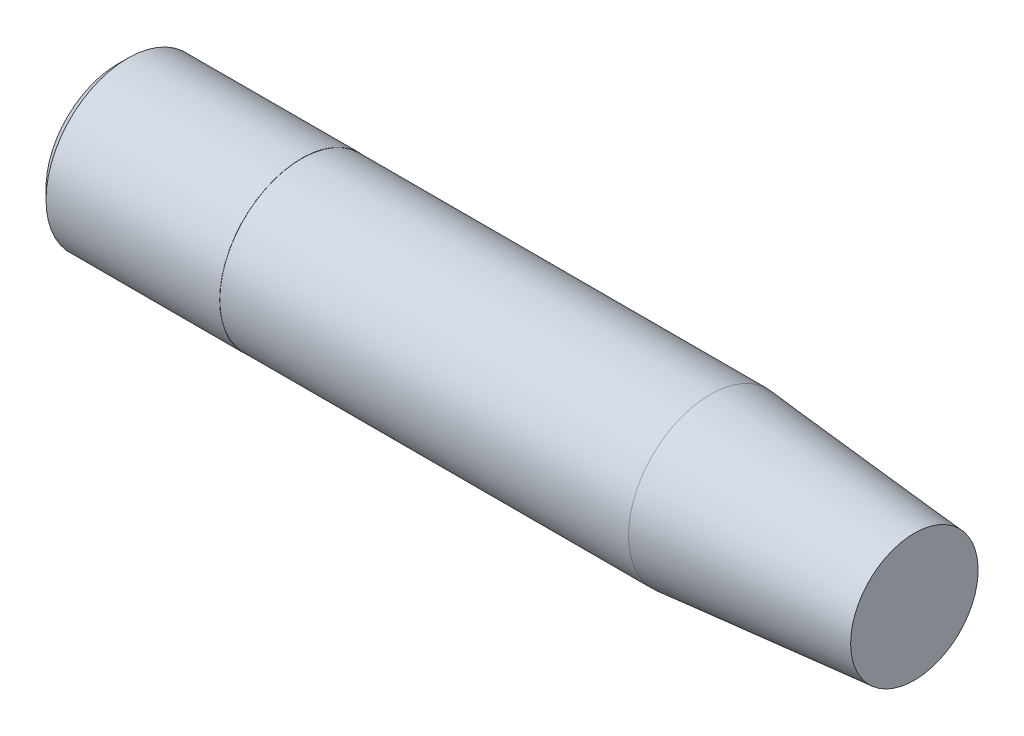
from build123d import *

# Parameters (mm, degrees)
FILLET1_R = 0.25


with BuildPart() as part:
    # Sketch1 → Revolve1 (revolve)
    with BuildSketch(Plane.XY, mode=Mode.PRIVATE) as revolve1_sk:
        Polygon((0, 2.0025), (0, 3.5), (-1, 3.5), (-1, 0), (19.5, 0), (19.5, 1.560056682), (14.5, 1.9975), (4.5, 1.9975), (4.5, 2.0025), align=None)
    revolve(revolve1_sk.sketch.rotate(Axis((-30.167084044, 0, 0), (1, 0, 0)), 90), axis=Axis((-30.167084044, 0, 0), (1, 0, 0)))  # turned: the seam where the file's is

    # Fillet1
    fillet1_edges = [part.edges().sort_by_distance(p)[0] for p in [
        (0, 0, -2.0025),
    ]]
    fillet(fillet1_edges, radius=FILLET1_R)

    # Sketch2 → Cut-Revolve1 (revolve, cut)
    with BuildSketch(Plane.XY, mode=Mode.PRIVATE) as cut_revolve1_sk:
        Polygon((0.25, 2.0025), (0, 1.7525), (0, 0), (-1, 0), (-1, 3.5), (0, 3.5), align=None)
    revolve(cut_revolve1_sk.sketch.rotate(Axis((0, 0, 0), (-1, 0, 0)), 270), axis=Axis((0, 0, 0), (-1, 0, 0)), mode=Mode.SUBTRACT)  # turned: the seam where the file's is


solid = part.part
